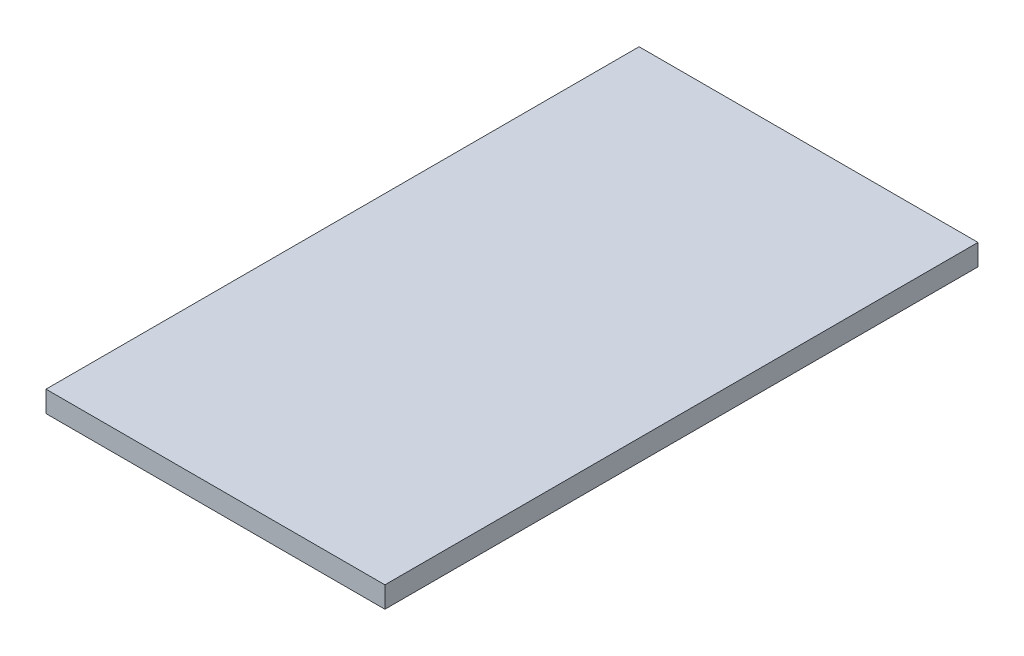
from build123d import *

# Parameters (mm, degrees)
SKETCH1_W           = 48
SKETCH1_H           = 84
BOSS_EXTRUDE1_DEPTH = 3


with BuildPart() as part:
    # Sketch1 → Boss-Extrude1 (new body)
    with BuildSketch(Plane(origin=(0, 0, 0), x_dir=(1, 0, 0), z_dir=(0, 1, 0))):
        Rectangle(SKETCH1_W, SKETCH1_H)
    extrude(amount=BOSS_EXTRUDE1_DEPTH)


solid = part.part
